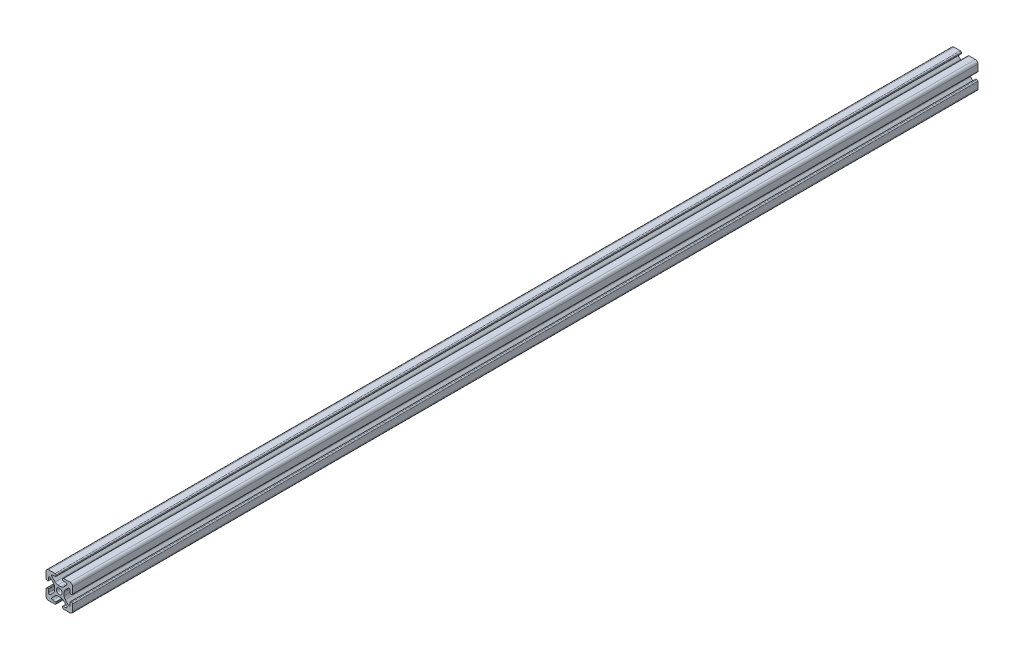
from build123d import *

# Parameters (mm, degrees)
SKETCH3_R           = 2.15
BOSS_EXTRUDE1_DEPTH = 680


with BuildPart() as part:
    # Sketch3 → Boss-Extrude1 (new body)
    with BuildSketch(Plane.XY):
        with BuildLine():
            Line((3.2874, 10), (8, 10))
            ThreePointArc((8, 10), (9.414213562, 9.414213562), (10, 8))
            Line((10, 8), (10, 3.2874))
            ThreePointArc((10, 3.2874), (9.76937588, 2.73062412), (9.2126, 2.5))
            Line((9.2126, 2.5), (8.5048, 2.5))
            ThreePointArc((8.5048, 2.5), (8.289273853, 2.589273853), (8.2, 2.8048))
            Line((8.2, 2.8048), (8.2, 4.9118))
            ThreePointArc((8.2, 4.9118), (7.682565253, 5.686195824), (6.769103096, 5.504496904))
            Line((6.769103096, 5.504496904), (4.478679656, 3.214073464))
            ThreePointArc((4.478679656, 3.214073464), (3.828361402, 2.240803418), (3.6, 1.092753121))
            Line((3.6, 1.092753121), (3.6, -1.092753121))
            ThreePointArc((3.6, -1.092753121), (3.828361402, -2.240803418), (4.478679656, -3.214073464))
            Line((4.478679656, -3.214073464), (6.769103096, -5.504496904))
            ThreePointArc((6.769103096, -5.504496904), (7.682565253, -5.686195824), (8.2, -4.9118))
            Line((8.2, -4.9118), (8.2, -2.8048))
            ThreePointArc((8.2, -2.8048), (8.289273853, -2.589273853), (8.5048, -2.5))
            Line((8.5048, -2.5), (9.2126, -2.5))
            ThreePointArc((9.2126, -2.5), (9.76937588, -2.73062412), (10, -3.2874))
            Line((10, -3.2874), (10, -8))
            ThreePointArc((10, -8), (9.414213562, -9.414213562), (8, -10))
            Line((8, -10), (3.2874, -10))
            ThreePointArc((3.2874, -10), (2.73062412, -9.76937588), (2.5, -9.2126))
            Line((2.5, -9.2126), (2.5, -8.5048))
            ThreePointArc((2.5, -8.5048), (2.589273853, -8.289273853), (2.8048, -8.2))
            Line((2.8048, -8.2), (4.9118, -8.2))
            ThreePointArc((4.9118, -8.2), (5.686195824, -7.682565253), (5.504496904, -6.769103096))
            Line((5.504496904, -6.769103096), (3.214073464, -4.478679656))
            ThreePointArc((3.214073464, -4.478679656), (2.240803418, -3.828361402), (1.092753121, -3.6))
            Line((1.092753121, -3.6), (-1.092753121, -3.6))
            ThreePointArc((-1.092753121, -3.6), (-2.240803418, -3.828361402), (-3.214073464, -4.478679656))
            Line((-3.214073464, -4.478679656), (-5.504496904, -6.769103096))
            ThreePointArc((-5.504496904, -6.769103096), (-5.686195824, -7.682565253), (-4.9118, -8.2))
            Line((-4.9118, -8.2), (-2.8048, -8.2))
            ThreePointArc((-2.8048, -8.2), (-2.589273853, -8.289273853), (-2.5, -8.5048))
            Line((-2.5, -8.5048), (-2.5, -9.2126))
            ThreePointArc((-2.5, -9.2126), (-2.73062412, -9.76937588), (-3.2874, -10))
            Line((-3.2874, -10), (-8, -10))
            ThreePointArc((-8, -10), (-9.414213562, -9.414213562), (-10, -8))
            Line((-10, -8), (-10, -3.2874))
            ThreePointArc((-10, -3.2874), (-9.76937588, -2.73062412), (-9.2126, -2.5))
            Line((-9.2126, -2.5), (-8.5048, -2.5))
            ThreePointArc((-8.5048, -2.5), (-8.289273853, -2.589273853), (-8.2, -2.8048))
            Line((-8.2, -2.8048), (-8.2, -4.9118))
            ThreePointArc((-8.2, -4.9118), (-7.682565253, -5.686195824), (-6.769103096, -5.504496904))
            Line((-6.769103096, -5.504496904), (-4.478679656, -3.214073464))
            ThreePointArc((-4.478679656, -3.214073464), (-3.828361402, -2.240803418), (-3.6, -1.092753121))
            Line((-3.6, -1.092753121), (-3.6, 1.092753121))
            ThreePointArc((-3.6, 1.092753121), (-3.828361402, 2.240803418), (-4.478679656, 3.214073464))
            Line((-4.478679656, 3.214073464), (-6.769103096, 5.504496904))
            ThreePointArc((-6.769103096, 5.504496904), (-7.682565253, 5.686195824), (-8.2, 4.9118))
            Line((-8.2, 4.9118), (-8.2, 2.8048))
            ThreePointArc((-8.2, 2.8048), (-8.289273853, 2.589273853), (-8.5048, 2.5))
            Line((-8.5048, 2.5), (-9.2126, 2.5))
            ThreePointArc((-9.2126, 2.5), (-9.76937588, 2.73062412), (-10, 3.2874))
            Line((-10, 3.2874), (-10, 8))
            ThreePointArc((-10, 8), (-9.414213562, 9.414213562), (-8, 10))
            Line((-8, 10), (-3.2874, 10))
            ThreePointArc((-3.2874, 10), (-2.73062412, 9.76937588), (-2.5, 9.2126))
            Line((-2.5, 9.2126), (-2.5, 8.5048))
            ThreePointArc((-2.5, 8.5048), (-2.589273853, 8.289273853), (-2.8048, 8.2))
            Line((-2.8048, 8.2), (-4.9118, 8.2))
            ThreePointArc((-4.9118, 8.2), (-5.686195824, 7.682565253), (-5.504496904, 6.769103096))
            Line((-5.504496904, 6.769103096), (-3.214073464, 4.478679656))
            ThreePointArc((-3.214073464, 4.478679656), (-2.240803418, 3.828361402), (-1.092753121, 3.6))
            Line((-1.092753121, 3.6), (1.092753121, 3.6))
            ThreePointArc((1.092753121, 3.6), (2.240803418, 3.828361402), (3.214073464, 4.478679656))
            Line((3.214073464, 4.478679656), (5.504496904, 6.769103096))
            ThreePointArc((5.504496904, 6.769103096), (5.686195824, 7.682565253), (4.9118, 8.2))
            Line((4.9118, 8.2), (2.8048, 8.2))
            ThreePointArc((2.8048, 8.2), (2.589273853, 8.289273853), (2.5, 8.5048))
            Line((2.5, 8.5048), (2.5, 9.2126))
            ThreePointArc((2.5, 9.2126), (2.73062412, 9.76937588), (3.2874, 10))
        make_face()
        Circle(SKETCH3_R, mode=Mode.SUBTRACT)
    extrude(amount=BOSS_EXTRUDE1_DEPTH)


solid = part.part
